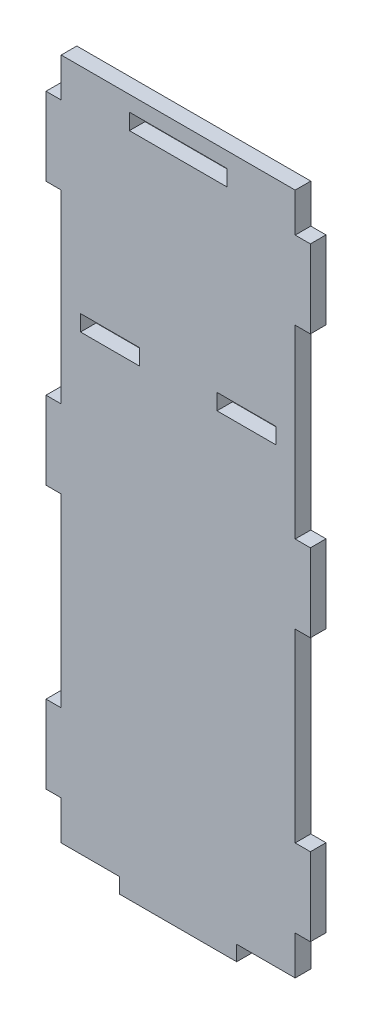
from build123d import *

# Parameters (mm, degrees)
SKETCH_1_W      = 4.1
SKETCH_1_H      = 15.1
SKETCH_1_H_2    = 25
EXTRUDE_1_DEPTH = 4


with BuildPart() as part:
    # ｽｹｯﾁ1 → ﾎﾞｽ - 押し出し1 (new body)
    with BuildSketch(Plane(origin=(0, 0, 0), x_dir=(0, 1, 0), z_dir=(0, 0, 1))):
        Polygon((165, 60), (165, 63.9), (145, 63.9), (145, 60), (97.5, 60), (97.5, 63.9), (77.5, 63.9), (77.5, 60), (30, 60), (30, 63.9), (10, 63.9), (10, 60), (0, 60), (0, 45), (-3.9, 45), (-3.9, 15), (0, 15), (0, 0), (10, 0), (10, -3.9), (30, -3.9), (30, 0), (77.5, 0), (77.5, -3.9), (97.5, -3.9), (97.5, 0), (145, 0), (145, -3.9), (165, -3.9), (165, 0), (175, 0), (175, 60), align=None)
        with Locations((118, 47.5)):
            Rectangle(SKETCH_1_W, SKETCH_1_H, mode=Mode.SUBTRACT)
        with Locations((118, 12.5)):
            Rectangle(SKETCH_1_W, SKETCH_1_H, mode=Mode.SUBTRACT)
        with Locations((169, 30)):
            Rectangle(SKETCH_1_W, SKETCH_1_H_2, mode=Mode.SUBTRACT)
    extrude(amount=EXTRUDE_1_DEPTH)


solid = part.part
